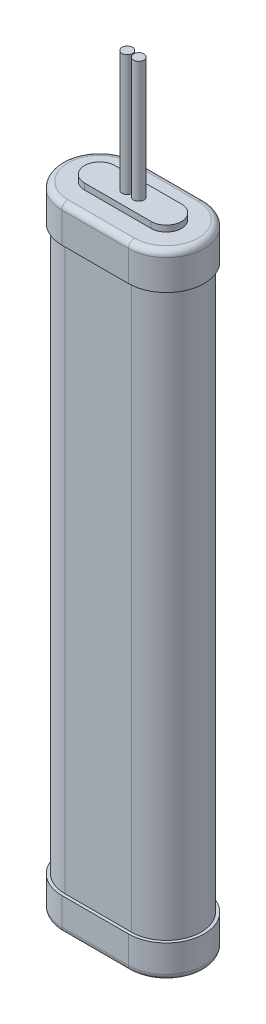
from build123d import *

# Parameters (mm, degrees)
EXTRUSION1_DEPTH = 11
EXTRUSION3_DEPTH = 186
EXTRUSION4_DEPTH = 12
EXTRUSION5_DEPTH = 2
CONG_1_R         = 2
ESQUISSE6_R      = 1.75
EXTRUSION6_DEPTH = 40


with BuildPart() as part:
    # Esquisse1 → Extrusion1 (new body)
    with BuildSketch(Plane(origin=(0, 0, 0), x_dir=(1, 0, 0), z_dir=(0, 1, 0))):
        with BuildLine():
            Line((0, 0), (22, 0))
            ThreePointArc((22, 0), (34.5, 12.5), (22, 25))
            Line((22, 25), (0, 25))
            ThreePointArc((0, 25), (-12.5, 12.5), (0, 0))
        make_face()
    extrude(amount=EXTRUSION1_DEPTH)

    # Esquisse3 → Extrusion3 (add)
    with BuildSketch(Plane(origin=(0, 11, 0), x_dir=(1, 0, 0), z_dir=(0, 1, 0))):
        with BuildLine():
            Line((0, 1), (22, 1))
            ThreePointArc((22, 1), (33.5, 12.5), (22, 24))
            Line((22, 24), (0, 24))
            ThreePointArc((0, 24), (-11.5, 12.5), (0, 1))
        make_face()
    extrude(amount=EXTRUSION3_DEPTH)

    # Esquisse4 → Extrusion4 (add)
    with BuildSketch(Plane(origin=(0, 197, 0), x_dir=(1, 0, 0), z_dir=(0, 1, 0))):
        with BuildLine():
            Line((0, 25), (22, 25))
            ThreePointArc((22, 25), (34.5, 12.5), (22, 0))
            Line((22, 0), (0, 0))
            ThreePointArc((0, 0), (-12.5, 12.5), (0, 25))
        make_face()
    extrude(amount=EXTRUSION4_DEPTH)

    # Esquisse5 → Extrusion5 (add)
    with BuildSketch(Plane(origin=(0, 209, 0), x_dir=(1, 0, 0), z_dir=(0, 1, 0))):
        with BuildLine():
            Line((0, 17.5), (22, 17.5))
            ThreePointArc((22, 17.5), (27, 12.5), (22, 7.5))
            Line((22, 7.5), (0, 7.5))
            ThreePointArc((0, 7.5), (-5, 12.5), (0, 17.5))
        make_face()
    extrude(amount=EXTRUSION5_DEPTH)

    # Congé1
    cong_1_edges = [part.edges().sort_by_distance(p)[0] for p in [
        (-12.5, 209, -12.5),
        (11, 209, 0),
        (34.5, 209, -12.5),
        (11, 209, -25),
        (11, 0, -25),
        (34.5, 0, -12.5),
        (11, 0, 0),
        (-12.5, 0, -12.5),
    ]]
    fillet(cong_1_edges, radius=CONG_1_R)

    # Esquisse6 → Extrusion6 (add)
    with BuildSketch(Plane(origin=(0, 211, 0), x_dir=(1, 0, 0), z_dir=(0, 1, 0))):
        with Locations((9.1, 12.5)):
            Circle(ESQUISSE6_R)
        with Locations((12.9, 12.5)):
            Circle(ESQUISSE6_R)
    extrude(amount=EXTRUSION6_DEPTH)


solid = part.part
